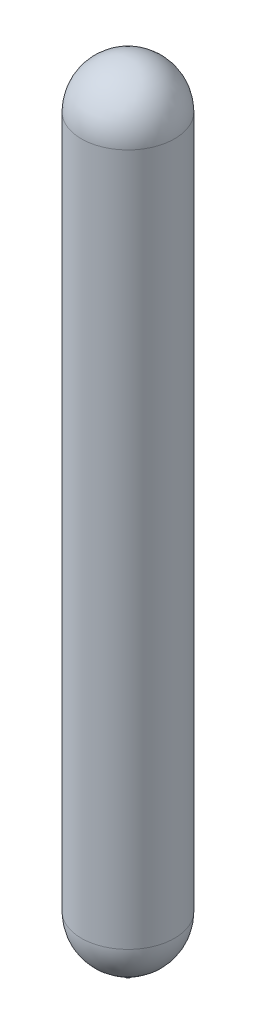
from build123d import *


with BuildPart() as part:
    # Sketch1 (on Front Plane) → Revolve1 (revolve)
    with BuildSketch(Plane.XY):
        with BuildLine():
            Line((-117.0432, 2112.02016), (-117.0432, 0))
            ThreePointArc((-117.0432, 0), (-83.877061305, -81.631790701), (-3.175, -117.000128381))
            Line((-3.175, -117.000128381), (-3.175, -167.046399365))
            Line((-3.175, -167.046399365), (-12.7, -167.046399365))
            Line((-12.7, -167.046399365), (-12.7, -138.305330063))
            ThreePointArc((-12.7, -138.305330063), (-102.600004298, -93.610327646), (-138.8872, 0))
            Line((-138.8872, 0), (-138.8872, 2112.02016))
            ThreePointArc((-138.8872, 2112.02016), (-98.20808094, 2210.22824094), (0, 2250.90736))
            Line((0, 2250.90736), (0, 2229.06336))
            ThreePointArc((0, 2229.06336), (-82.762040412, 2194.782200412), (-117.0432, 2112.02016))
        make_face()
    revolve(axis=Axis((0, 50.358015581, 0), (0, -1, 0)))


with BuildPart() as body_2:
    # Sketch1_4 → Revolve2 (revolve)
    with BuildSketch(Plane.XY):
        with BuildLine():
            ThreePointArc((-138.8872, 2112.02016), (-98.20808094, 2210.22824094), (0, 2250.90736))
            Line((0, 2250.90736), (0, 2254.23476))
            ThreePointArc((0, 2254.23476), (-100.560908044, 2212.581068044), (-142.2146, 2112.02016))
            Line((-142.2146, 2112.02016), (-142.2146, 0))
            ThreePointArc((-142.2146, 0), (-104.955032926, -95.965793471), (-12.7, -141.646399365))
            Line((-12.7, -141.646399365), (-12.7, -138.305330063))
            ThreePointArc((-12.7, -138.305330063), (-102.600004298, -93.610327646), (-138.8872, 0))
            Line((-138.8872, 0), (-138.8872, 2112.02016))
        make_face()
    revolve(axis=Axis((0, 50.358015581, 0), (0, -1, 0)))


solid = Compound([part.part, body_2.part])
